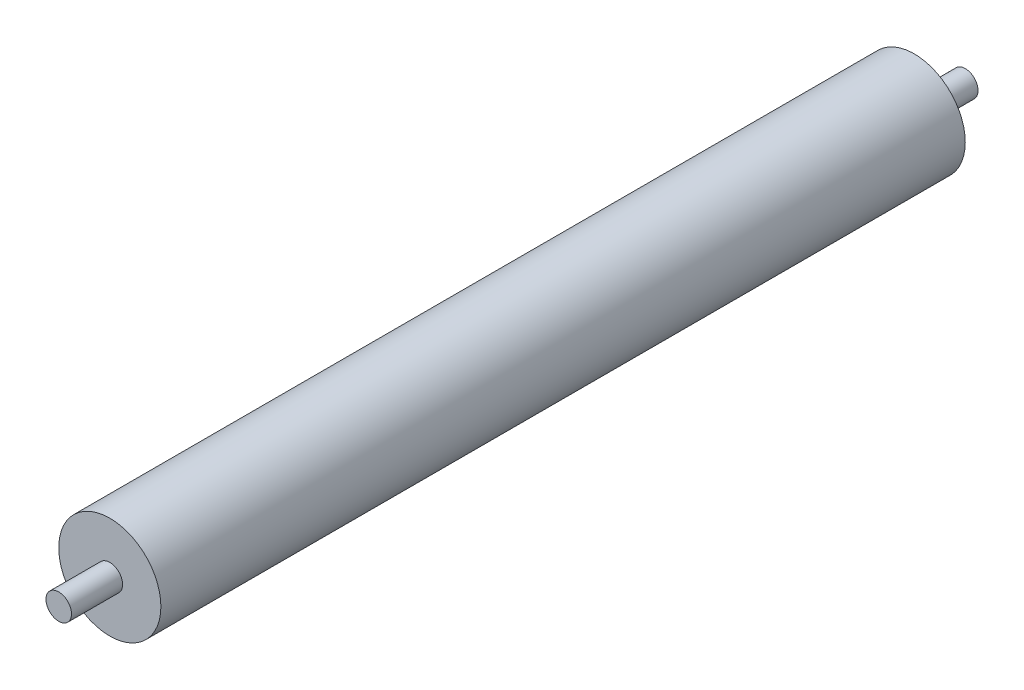
from build123d import *

# Parameters (mm, degrees)
SKETCH1_R           = 20
BOSS_EXTRUDE1_DEPTH = 315
SKETCH2_R           = 5
BOSS_EXTRUDE2_DEPTH = 20
SKETCH3_R           = 5
BOSS_EXTRUDE3_DEPTH = 20


with BuildPart() as part:
    # Sketch1 → Boss-Extrude1 (new body)
    with BuildSketch(Plane.XY):
        Circle(SKETCH1_R)
    extrude(amount=BOSS_EXTRUDE1_DEPTH)

    # Sketch2 → Boss-Extrude2 (add)
    with BuildSketch(Plane.XY.offset(315)):
        Circle(SKETCH2_R)
    extrude(amount=BOSS_EXTRUDE2_DEPTH)

    # Sketch3 → Boss-Extrude3 (add)
    with BuildSketch(Plane(origin=(0, 0, 0), x_dir=(-1, 0, 0), z_dir=(0, 0, -1))):
        Circle(SKETCH3_R)
    extrude(amount=BOSS_EXTRUDE3_DEPTH)


solid = part.part
